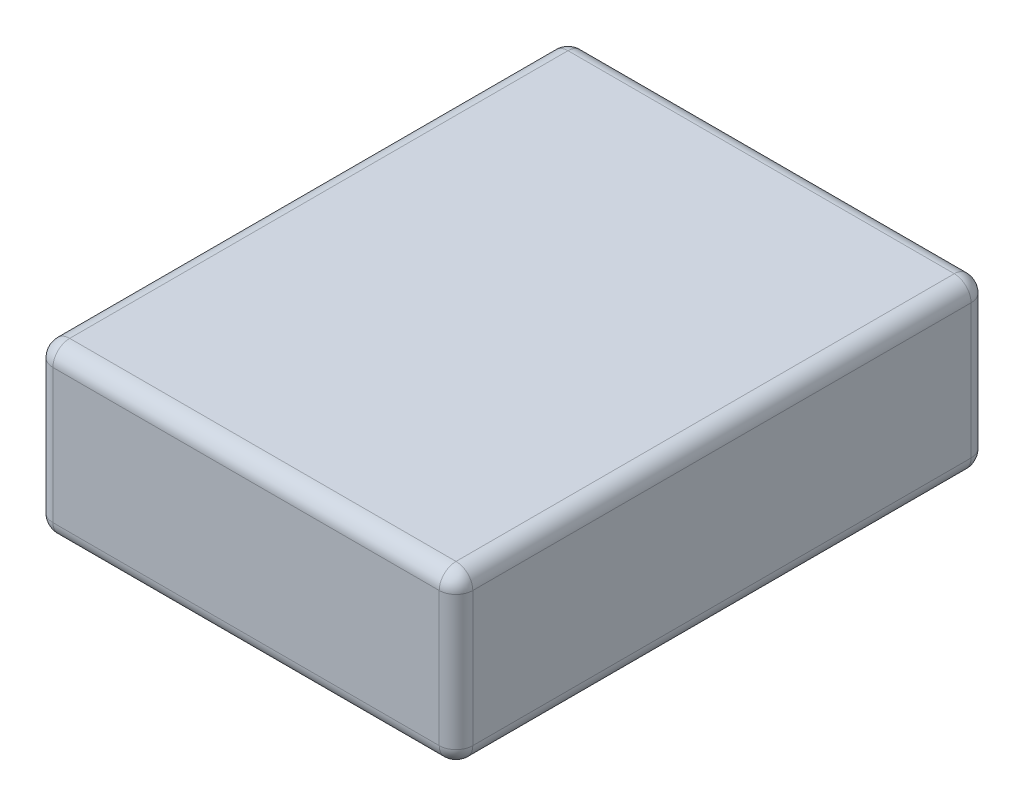
from build123d import *

# Parameters (mm, degrees)
SKETCH1_W           = 7.5
SKETCH1_H           = 3
BOSS_EXTRUDE1_DEPTH = 9.5
FILLET1_R           = 0.3


with BuildPart() as part:
    # Sketch1 → Boss-Extrude1 (new body)
    with BuildSketch(Plane.XY):
        Rectangle(SKETCH1_W, SKETCH1_H)
    extrude(amount=BOSS_EXTRUDE1_DEPTH)

    # Fillet1
    fillet1_edges = [part.edges().sort_by_distance(p)[0] for p in [
        (-3.75, 0, 9.5),
        (0, -1.5, 9.5),
        (3.75, 0, 9.5),
        (0, -1.5, 0),
        (-3.75, 0, 0),
        (0, 1.5, 0),
        (3.75, 0, 0),
        (3.75, -1.5, 4.75),
        (-3.75, -1.5, 4.75),
        (-3.75, 1.5, 4.75),
        (3.75, 1.5, 4.75),
        (0, 1.5, 9.5),
    ]]
    fillet(fillet1_edges, radius=FILLET1_R)


solid = part.part
